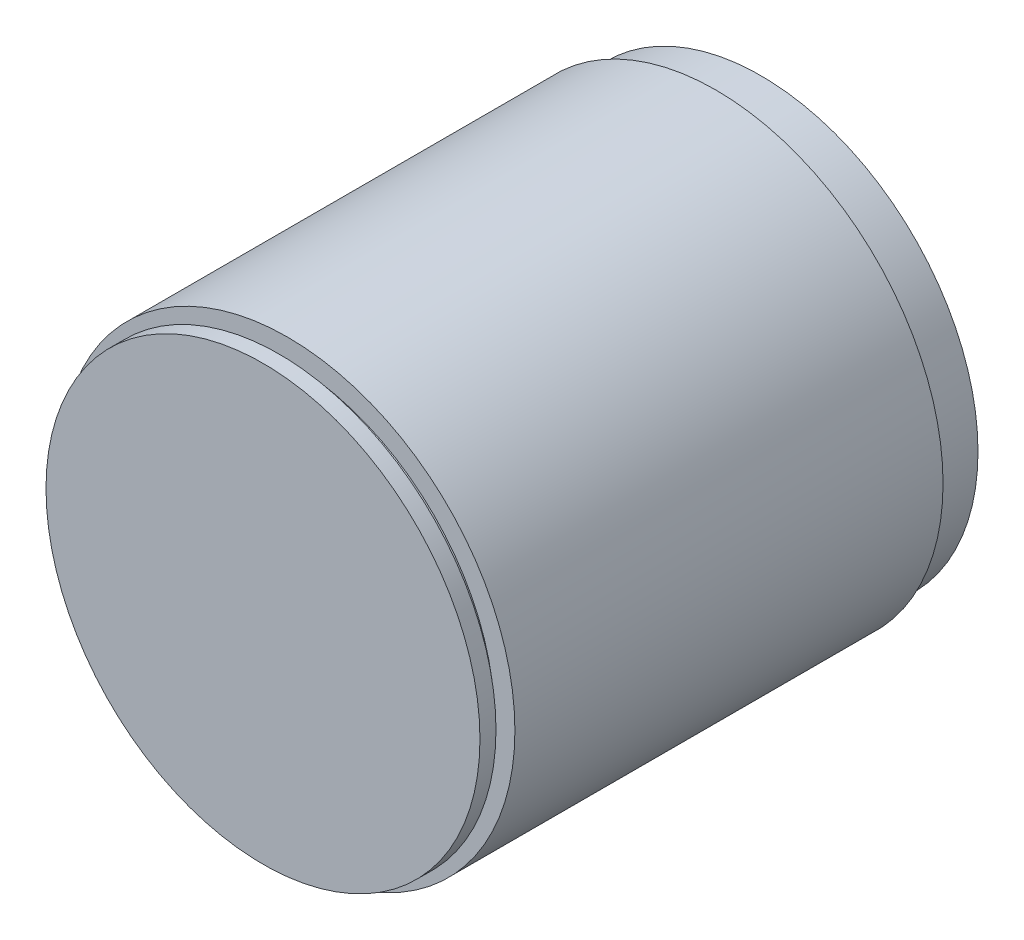
from build123d import *


with BuildPart() as part:
    # Croquis1 → Revolución1 (revolve)
    with BuildSketch(Plane(origin=(0, 0, 0), x_dir=(1, 0, 0), z_dir=(0, 1, 0))):
        Polygon((101.811190524, -88.124308779), (173.367168769, -88.124308779), (173.367168769, -82.841652667), (170.005478516, -82.841652667), (170.005478516, -79.960203878), (176.728859022, -79.960203878), (176.728859022, 61.230786754), (173.367168769, 61.230786754), (173.367168769, 67.95416726), (173.367168769, 76.11827216), (101.811190524, 76.11827216), align=None)
    revolve(axis=Axis((101.811190524, 0, -76.11827216), (0, 0, 1)))


solid = part.part
